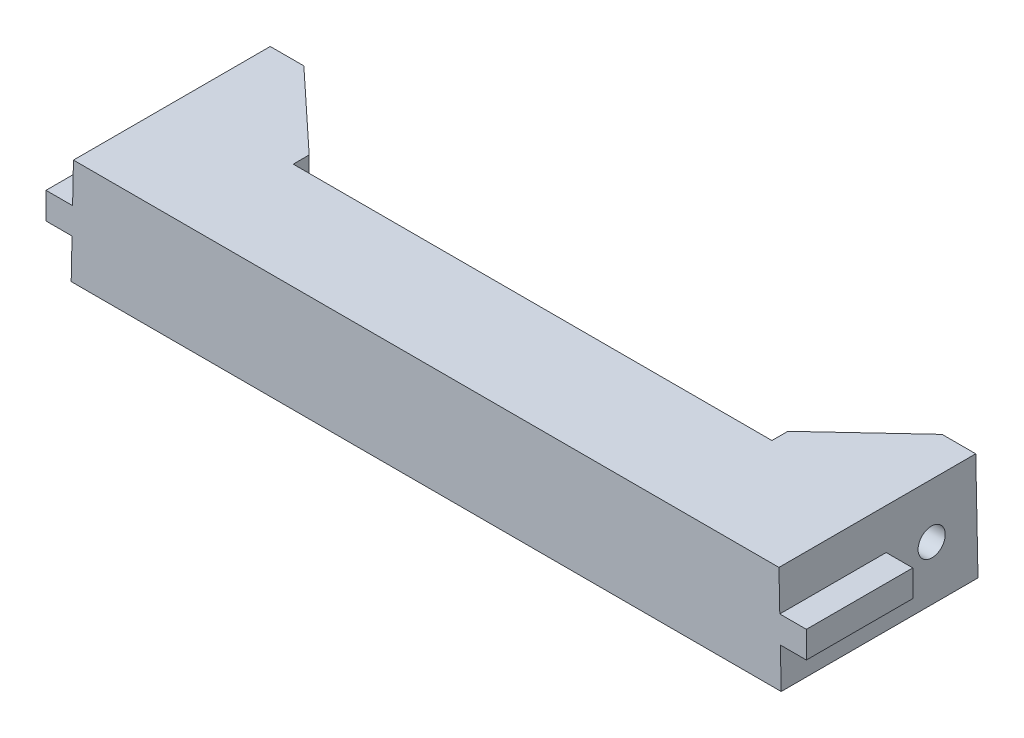
from build123d import *

# Parameters (mm, degrees)
BOSS_EXTRUDE1_DEPTH = 20
SKETCH3_W           = 17
SKETCH3_H           = 20
SKETCH2_W           = 17
SKETCH2_H           = 20.004497681
SKETCH5_W           = 5
SKETCH5_H           = 5
BOSS_EXTRUDE2_DEPTH = 20
SKETCH6_R           = 2.55
CUT_EXTRUDE1_DEPTH  = 12.47988838
SKETCH8_W           = 17
SKETCH8_H           = 20
SKETCH7_W           = 3
SKETCH7_H           = 20
SKETCH9_R           = 6.5
CUT_EXTRUDE2_DEPTH  = 30


with BuildPart() as part:
    # Sketch1 → Boss-Extrude1 (new body)
    with BuildSketch(Plane.XY):
        Polygon((-66.745, 0), (66.745, 0), (66.320821408, 20), (-66.320821408, 20), align=None)
    extrude(amount=BOSS_EXTRUDE1_DEPTH)

    # Sketch3 → Loft1 section 0
    with BuildSketch(Plane(origin=(60, 0, 0), x_dir=(0, 0, -1), z_dir=(1, 0, 0))):
        with Locations((8.5, 10)):
            Rectangle(SKETCH3_W, SKETCH3_H)
    # Sketch2 → Loft1 section 1
    with BuildSketch(Plane(origin=(66.71499035, 1.414953534, 0), x_dir=(0, 0, -1), z_dir=(0.999775167, 0.021204161, 0))):
        with Locations((8.5, 8.586977106)):
            Rectangle(SKETCH2_W, SKETCH2_H)
    loft1 = loft()

    # Sketch5 → Boss-Extrude2 (add)
    with BuildSketch(Plane.XY.offset(20)):
        with Locations((68.97988838, 10)):
            Rectangle(SKETCH5_W, SKETCH5_H)
    boss_extrude2 = extrude(amount=-BOSS_EXTRUDE2_DEPTH)

    # Mirror2: Boss-Extrude2 across plane
    add(boss_extrude2.mirror(Plane(origin=(0, 0, 0), x_dir=(0, 0, 1), z_dir=(1, 0, 0))))

    # Sketch6 → Cut-Extrude1 (cut, through all)
    with BuildSketch(Plane.ZY.offset(-60)):
        with Locations((-8.5, 10)):
            Circle(SKETCH6_R)
    cut_extrude1 = extrude(amount=-CUT_EXTRUDE1_DEPTH, mode=Mode.SUBTRACT)

    # Sketch8 → Loft2 section 0
    with BuildSketch(Plane.ZY.offset(-60)):
        with Locations((-8.5, 10)):
            Rectangle(SKETCH8_W, SKETCH8_H)
    # Sketch7 → Loft2 section 1
    with BuildSketch(Plane(origin=(45, 0, 0), x_dir=(0, 0, -1), z_dir=(1, 0, 0))):
        with Locations((1.5, 10)):
            Rectangle(SKETCH7_W, SKETCH7_H)
    loft2 = loft()

    # Sketch9 → Cut-Extrude2 (cut)
    with BuildSketch(Plane(origin=(60, 0, 0), x_dir=(0, 0, -1), z_dir=(1, 0, 0))):
        with Locations((8.5, 10)):
            Circle(SKETCH9_R)
    cut_extrude2 = extrude(amount=-CUT_EXTRUDE2_DEPTH, mode=Mode.SUBTRACT)

    # Mirror3: Loft1, Cut-Extrude1, Loft2, Cut-Extrude2 across plane
    add(loft1.mirror(Plane(origin=(0, 0, 0), x_dir=(0, 0, 1), z_dir=(1, 0, 0))))
    add(cut_extrude1.mirror(Plane(origin=(0, 0, 0), x_dir=(0, 0, 1), z_dir=(1, 0, 0))), mode=Mode.SUBTRACT)
    add(loft2.mirror(Plane(origin=(0, 0, 0), x_dir=(0, 0, 1), z_dir=(1, 0, 0))))
    add(cut_extrude2.mirror(Plane(origin=(0, 0, 0), x_dir=(0, 0, 1), z_dir=(1, 0, 0))), mode=Mode.SUBTRACT)


solid = part.part
